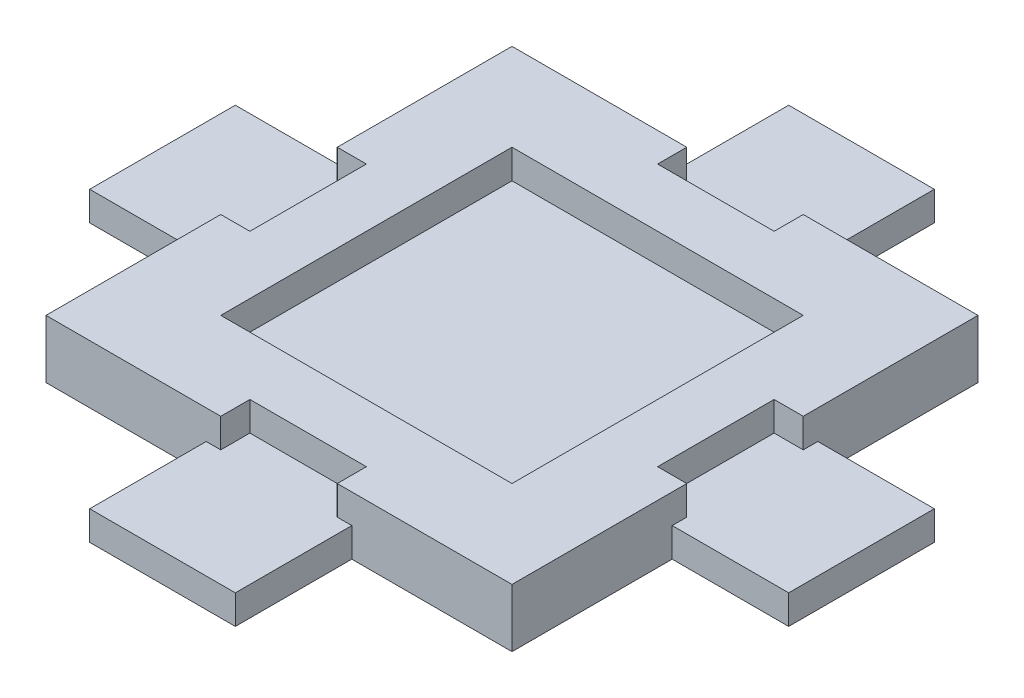
from build123d import *

# Parameters (mm, degrees)
SKETCH1_W           = 101.6
SKETCH1_H           = 101.6
BOSS_EXTRUDE1_DEPTH = 12.7
SKETCH7_W           = 63.5
SKETCH7_H           = 63.5
CUT_EXTRUDE2_DEPTH  = 6.35
SKETCH8_W           = 25.4
SKETCH8_H           = 6.35
CUT_EXTRUDE3_DEPTH  = 6.35
CIRPATTERN2_COUNT   = 4
BOSS_EXTRUDE3_START = -6.35
SKETCH9_W           = 31.75
SKETCH9_H           = 25.4
BOSS_EXTRUDE3_DEPTH = 6.35
CIRPATTERN3_COUNT   = 4


with BuildPart() as part:
    # Sketch1 → Boss-Extrude1 (new body)
    with BuildSketch(Plane(origin=(0, 0, 0), x_dir=(1, 0, 0), z_dir=(0, 1, 0))):
        with Locations((50.8, 50.8)):
            Rectangle(SKETCH1_W, SKETCH1_H)
    extrude(amount=BOSS_EXTRUDE1_DEPTH)

    # Sketch7 → Cut-Extrude2 (cut)
    with BuildSketch(Plane(origin=(0, 12.7, 0), x_dir=(1, 0, 0), z_dir=(0, 1, 0))):
        with Locations((50.8, 50.8)):
            Rectangle(SKETCH7_W, SKETCH7_H)
    extrude(amount=-CUT_EXTRUDE2_DEPTH, mode=Mode.SUBTRACT)

    # Sketch8 → Cut-Extrude3 (cut)
    with BuildSketch(Plane(origin=(0, 12.7, 0), x_dir=(1, 0, 0), z_dir=(0, 1, 0))):
        with Locations((50.8, 98.425)):
            Rectangle(SKETCH8_W, SKETCH8_H)
    cut_extrude3 = extrude(amount=-CUT_EXTRUDE3_DEPTH, mode=Mode.SUBTRACT)

    # CirPattern2: Cut-Extrude3 ×4 about axis
    cirpattern2_axis = Axis((50.8, 6.35, -50.8), (0, 1, 0))
    for i in range(1, CIRPATTERN2_COUNT):
        add(cut_extrude3.rotate(cirpattern2_axis, i * 360 / CIRPATTERN2_COUNT), mode=Mode.SUBTRACT)

    # Sketch9 → Boss-Extrude3 (add)
    with BuildSketch(Plane(origin=(0, 12.7, 0), x_dir=(1, 0, 0), z_dir=(0, 1, 0)).offset(BOSS_EXTRUDE3_START)):
        with Locations((50.8, 114.3)):
            Rectangle(SKETCH9_W, SKETCH9_H)
    boss_extrude3 = extrude(amount=-BOSS_EXTRUDE3_DEPTH)

    # CirPattern3: Boss-Extrude3 ×4 about axis
    cirpattern3_axis = Axis((50.8, 6.35, -50.8), (0, 1, 0))
    for i in range(1, CIRPATTERN3_COUNT):
        add(boss_extrude3.rotate(cirpattern3_axis, i * 360 / CIRPATTERN3_COUNT))


solid = part.part
